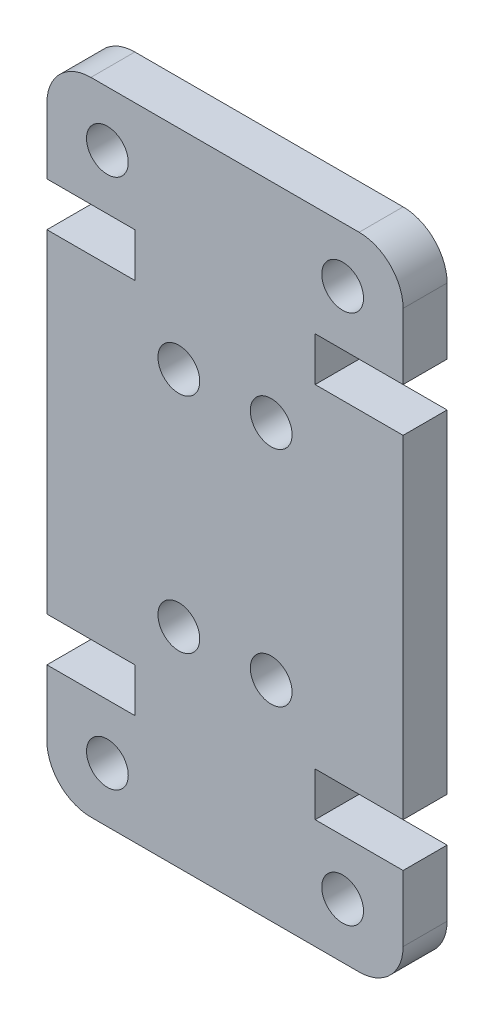
from build123d import *

# Parameters (mm, degrees)
SKETCH1_R           = 0.95
BOSS_EXTRUDE1_DEPTH = 2


with BuildPart() as part:
    # Sketch1 → Boss-Extrude1 (new body)
    with BuildSketch(Plane.XY):
        with BuildLine():
            Line((0, 22.14), (0, 7))
            Line((0, 7), (4, 7))
            Line((4, 7), (4, 5))
            Line((4, 5), (0, 5))
            Line((0, 5), (0, 2))
            ThreePointArc((0, 2), (0.585786438, 0.585786438), (2, 0))
            Line((2, 0), (14.2, 0))
            ThreePointArc((14.2, 0), (15.614213562, 0.585786438), (16.2, 2))
            Line((16.2, 2), (16.2, 5))
            Line((16.2, 5), (12.2, 5))
            Line((12.2, 5), (12.2, 7))
            Line((12.2, 7), (16.2, 7))
            Line((16.2, 7), (16.2, 22.14))
            Line((16.2, 22.14), (12.2, 22.14))
            Line((12.2, 22.14), (12.2, 24.14))
            Line((12.2, 24.14), (16.2, 24.14))
            Line((16.2, 24.14), (16.2, 27.14))
            ThreePointArc((16.2, 27.14), (15.614213562, 28.554213562), (14.2, 29.14))
            Line((14.2, 29.14), (2, 29.14))
            ThreePointArc((2, 29.14), (0.585786438, 28.554213562), (0, 27.14))
            Line((0, 27.14), (0, 24.14))
            Line((0, 24.14), (4, 24.14))
            Line((4, 24.14), (4, 22.14))
            Line((4, 22.14), (0, 22.14))
        make_face()
        with Locations((13.45, 2.5)):
            Circle(SKETCH1_R, mode=Mode.SUBTRACT)
        with Locations((10.2, 9.5)):
            Circle(SKETCH1_R, mode=Mode.SUBTRACT)
        with Locations((2.75, 26.64)):
            Circle(SKETCH1_R, mode=Mode.SUBTRACT)
        with Locations((6, 19.64)):
            Circle(SKETCH1_R, mode=Mode.SUBTRACT)
        with Locations((6, 9.5)):
            Circle(SKETCH1_R, mode=Mode.SUBTRACT)
        with Locations((2.75, 2.5)):
            Circle(SKETCH1_R, mode=Mode.SUBTRACT)
        with Locations((10.2, 19.64)):
            Circle(SKETCH1_R, mode=Mode.SUBTRACT)
        with Locations((13.45, 26.64)):
            Circle(SKETCH1_R, mode=Mode.SUBTRACT)
    extrude(amount=BOSS_EXTRUDE1_DEPTH)


solid = part.part
